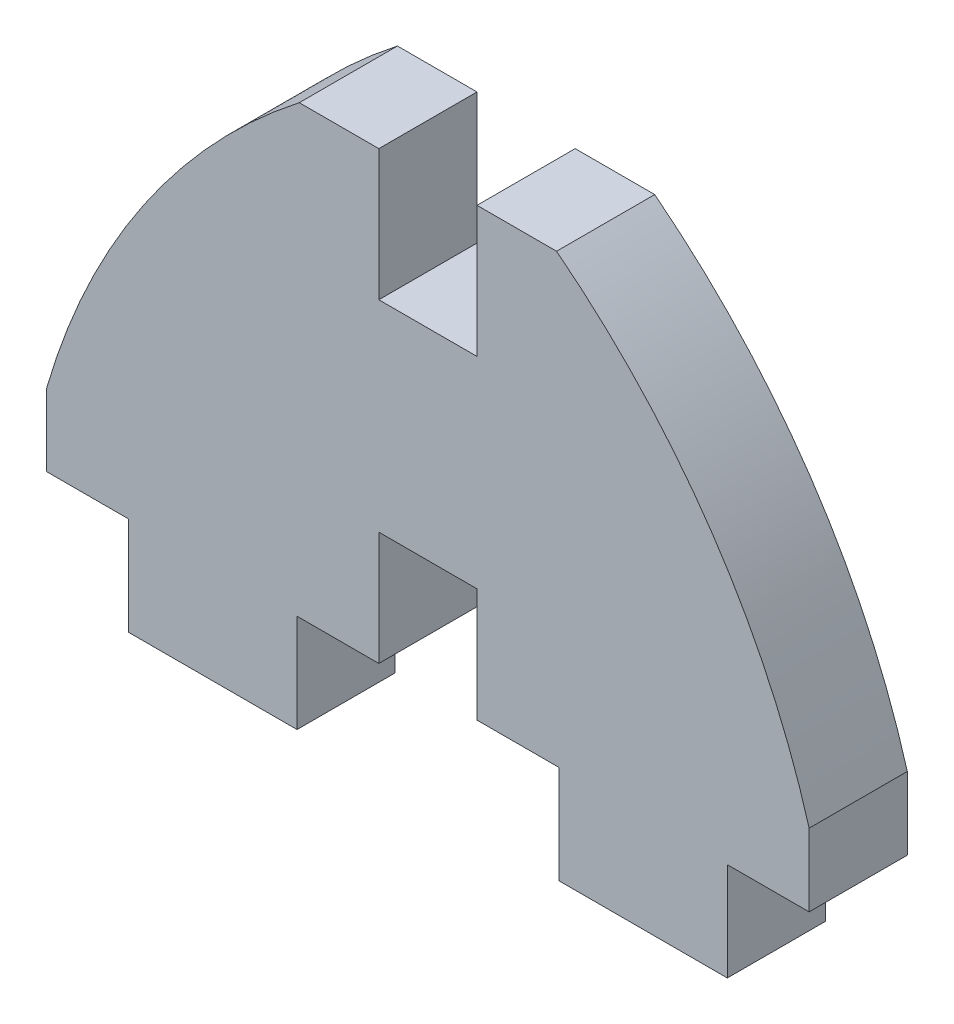
from build123d import *

# Parameters (mm, degrees)
BOSS_EXTRUDE1_DEPTH = 6


with BuildPart() as part:
    # Sketch1 → Boss-Extrude1 (new body)
    with BuildSketch(Plane.XY):
        with BuildLine():
            Line((3, 0), (-3, 0))
            Line((-3, 0), (-3, -6.95))
            Line((-3, -6.95), (-8, -6.95))
            Line((-8, -6.95), (-8, -12.95))
            Line((-8, -12.95), (-18.3, -12.95))
            Line((-18.3, -12.95), (-18.3, -6.95))
            Line((-18.3, -6.95), (-23.3, -6.95))
            Line((-23.3, -6.95), (-23.3, -2.518518519))
            ThreePointArc((-23.3, -2.518518519), (-17.386420004, 10.11168629), (-7.863250069, 20.3))
            Line((-7.863250069, 20.3), (-3, 20.3))
            Line((-3, 20.3), (-3, 12.3))
            Line((-3, 12.3), (3, 12.3))
            Line((3, 12.3), (3, 20.3))
            Line((3, 20.3), (7.863250069, 20.3))
            ThreePointArc((7.863250069, 20.3), (17.386420004, 10.11168629), (23.3, -2.518518519))
            Line((23.3, -2.518518519), (23.3, -6.95))
            Line((23.3, -6.95), (18.3, -6.95))
            Line((18.3, -6.95), (18.3, -12.95))
            Line((18.3, -12.95), (8, -12.95))
            Line((8, -12.95), (8, -6.95))
            Line((8, -6.95), (3, -6.95))
            Line((3, -6.95), (3, 0))
        make_face()
    extrude(amount=BOSS_EXTRUDE1_DEPTH)


solid = part.part
